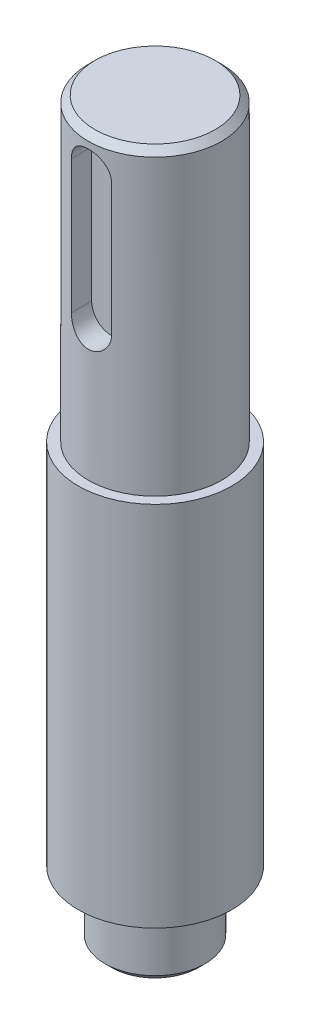
from build123d import *

# Parameters (mm, degrees)
CHAMFER_1_SIZE      = 1
CUT_EXTRUDE_1_DEPTH = 6
CHAMFER_2_SIZE      = 1


with BuildPart() as part:
    # 草图1 → 旋转1 (revolve)
    with BuildSketch(Plane.XY):
        Polygon((0, 0), (10, 0), (10, -45), (11.5, -45), (11.5, -100), (7.5, -100), (7.5, -110), (0, -110), align=None)
    revolve(axis=Axis((0, -110, 0), (0, 1, 0)))

    # 倒角1
    chamfer_1_edges = [part.edges().sort_by_distance(p)[0] for p in [
        (-10, 0, 0),
    ]]
    chamfer(chamfer_1_edges, length=CHAMFER_1_SIZE)

    # 草图2 → 切除-拉伸1 (cut, through all)
    with BuildSketch(Plane.XY.offset(6.5)):
        with BuildLine():
            Line((3, -5), (3, -25))
            ThreePointArc((3, -25), (0, -28), (-3, -25))
            Line((-3, -25), (-3, -5))
            ThreePointArc((-3, -5), (0, -2), (3, -5))
        make_face()
    extrude(amount=CUT_EXTRUDE_1_DEPTH, mode=Mode.SUBTRACT)

    # 倒角2
    chamfer_2_edges = [part.edges().sort_by_distance(p)[0] for p in [
        (-7.5, -110, 0),
    ]]
    chamfer(chamfer_2_edges, length=CHAMFER_2_SIZE)


solid = part.part
